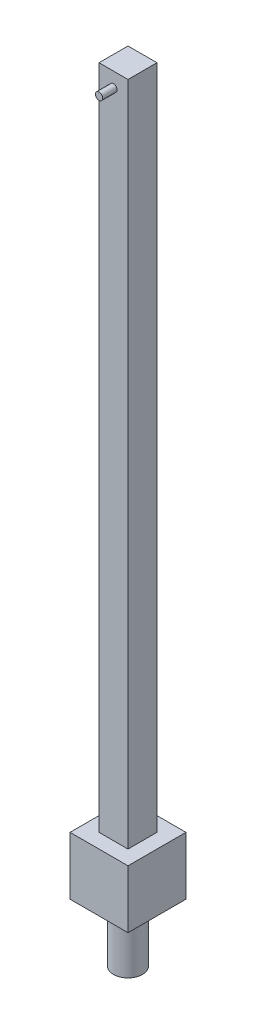
from build123d import *

# Parameters (mm, degrees)
SKETCH1_W           = 20
SKETCH1_H           = 20
BOSS_EXTRUDE1_DEPTH = 500
SKETCH2_W           = 40
SKETCH2_H           = 40
BOSS_EXTRUDE2_DEPTH = 40
SKETCH3_R           = 10
BOSS_EXTRUDE3_DEPTH = 40
SKETCH4_R           = 2.5
BOSS_EXTRUDE4_DEPTH = 10


with BuildPart() as part:
    # Sketch1 → Boss-Extrude1 (new body)
    with BuildSketch(Plane(origin=(0, 0, 0), x_dir=(1, 0, 0), z_dir=(0, 1, 0))):
        Rectangle(SKETCH1_W, SKETCH1_H)
    extrude(amount=BOSS_EXTRUDE1_DEPTH)

    # Sketch2 → Boss-Extrude2 (add)
    with BuildSketch(Plane.XZ):
        Rectangle(SKETCH2_W, SKETCH2_H)
    extrude(amount=-BOSS_EXTRUDE2_DEPTH)

    # Sketch3 → Boss-Extrude3 (add)
    with BuildSketch(Plane.XZ):
        Circle(SKETCH3_R)
    extrude(amount=BOSS_EXTRUDE3_DEPTH)

    # Sketch4 → Boss-Extrude4 (add)
    with BuildSketch(Plane.XY.offset(10)):
        with Locations((0, 490)):
            Circle(SKETCH4_R)
    extrude(amount=BOSS_EXTRUDE4_DEPTH)


solid = part.part
